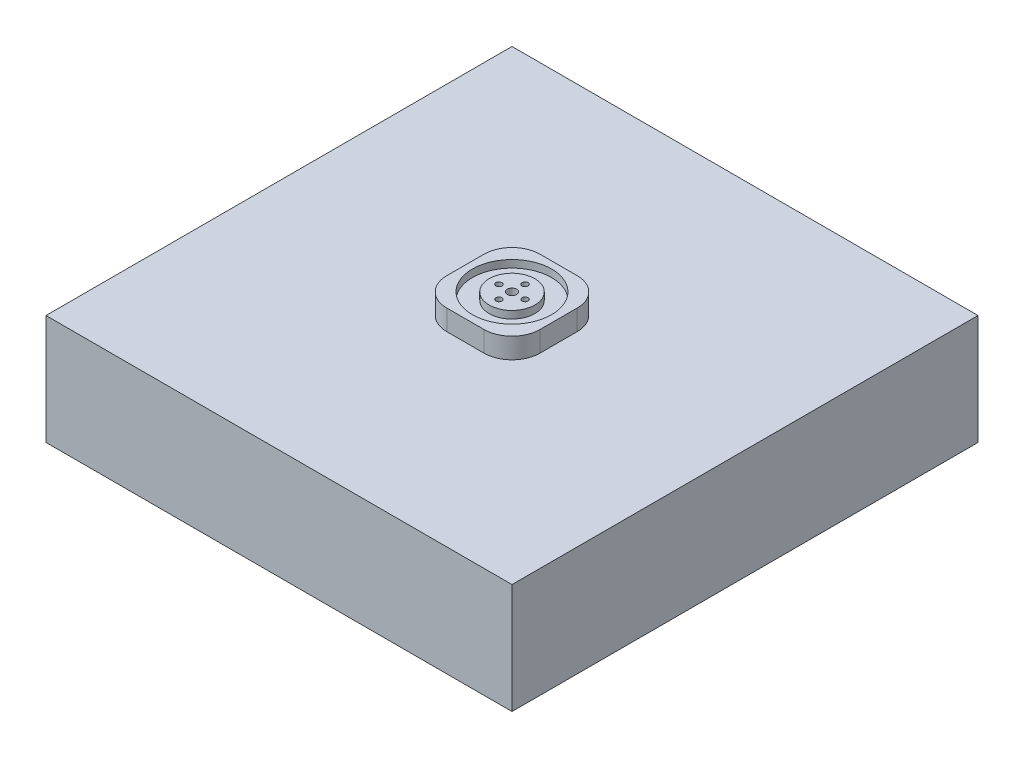
from build123d import *

# Parameters (mm, degrees)
BOSS_EXTRUDE1_DEPTH          = 44
SKETCH3_W                    = 50
SKETCH3_H                    = 50
BOSS_EXTRUDE2_DEPTH          = 11
SKETCH4_R                    = 21.25
SKETCH4_R_2                  = 12.25
CUT_EXTRUDE1_DEPTH           = 4
SKETCH5_3_R                  = 1.6
CUT_EXTRUDE3_DEPTH           = 20
SKETCH5_R                    = 2.5
CUT_EXTRUDE4_DEPTH           = 5
FILLET2_R                    = 15
SKETCH8_R                    = 3
CUT_EXTRUDE5_DEPTH           = 15
SCHIZZO2_W                   = 250
SCHIZZO2_H                   = 250
SCHIZZO2_W_2                 = 25.273765435
SCHIZZO2_H_2                 = 26.723899517
ESTRUSIONE_ESTRUSIONE1_DEPTH = 9
SCHIZZO5_W                   = 250
SCHIZZO5_H                   = 250
SCHIZZO5_W_2                 = 121.71
SCHIZZO5_H_2                 = 121.711825152
ESTRUSIONE_ESTRUSIONE2_DEPTH = 50


with BuildPart() as part:
    # Sketch1 → Boss-Extrude1 (new body)
    with BuildSketch(Plane.XY):
        Polygon((-22.5, 0), (22.5, 0), (18, 9), (-18, 9), align=None)
    extrude(amount=BOSS_EXTRUDE1_DEPTH)

    # Sketch3 → Boss-Extrude2 (add)
    with BuildSketch(Plane(origin=(0, 9, 0), x_dir=(1, 0, 0), z_dir=(0, 1, 0))):
        with Locations((0, -22)):
            Rectangle(SKETCH3_W, SKETCH3_H)
    extrude(amount=BOSS_EXTRUDE2_DEPTH)

    # Sketch4 → Cut-Extrude1 (cut)
    with BuildSketch(Plane(origin=(0, 20, 0), x_dir=(1, 0, 0), z_dir=(0, 1, 0))):
        with Locations((0, -22)):
            Circle(SKETCH4_R)
        with Locations((0, -22)):
            Circle(SKETCH4_R_2, mode=Mode.SUBTRACT)
    extrude(amount=-CUT_EXTRUDE1_DEPTH, mode=Mode.SUBTRACT)

    # Sketch5_3 → Cut-Extrude3 (cut)
    with BuildSketch(Plane(origin=(0, 20, 0), x_dir=(1, 0, 0), z_dir=(0, 1, 0))):
        with Locations((0, -15)):
            Circle(SKETCH5_3_R)
        with Locations((-7, -22)):
            Circle(SKETCH5_3_R)
        with Locations((7, -22)):
            Circle(SKETCH5_3_R)
        with Locations((0, -29)):
            Circle(SKETCH5_3_R)
    extrude(amount=-CUT_EXTRUDE3_DEPTH, mode=Mode.SUBTRACT)

    # Sketch5 → Cut-Extrude4 (cut)
    with BuildSketch(Plane(origin=(0, 20, 0), x_dir=(1, 0, 0), z_dir=(0, 1, 0))):
        with Locations((0, -22)):
            Circle(SKETCH5_R)
    extrude(amount=-CUT_EXTRUDE4_DEPTH, mode=Mode.SUBTRACT)

    # Fillet2
    fillet2_edges = [part.edges().sort_by_distance(p)[0] for p in [
        (25, 14.5, 47),
        (25, 14.5, -3),
        (-25, 14.5, -3),
        (-25, 14.5, 47),
    ]]
    fillet(fillet2_edges, radius=FILLET2_R)

    # Sketch8 → Cut-Extrude5 (cut)
    with BuildSketch(Plane(origin=(0, 0, 0), x_dir=(-1, 0, 0), z_dir=(0, -1, 0))):
        with Locations((0, -29)):
            Circle(SKETCH8_R)
        with Locations((-7, -22)):
            Circle(SKETCH8_R)
        with Locations((0, -15)):
            Circle(SKETCH8_R)
        with Locations((7, -22)):
            Circle(SKETCH8_R)
    extrude(amount=-CUT_EXTRUDE5_DEPTH, mode=Mode.SUBTRACT)

    # Schizzo2 → Estrusione-Estrusione1 (add)
    with BuildSketch(Plane.XZ):
        with Locations((0, 22)):
            Rectangle(SCHIZZO2_W, SCHIZZO2_H)
        with Locations((-0.310743018, 21.585675977)):
            Rectangle(SCHIZZO2_W_2, SCHIZZO2_H_2, mode=Mode.SUBTRACT)
    extrude(amount=-ESTRUSIONE_ESTRUSIONE1_DEPTH)

    # Schizzo5 → Estrusione-Estrusione2 (add)
    with BuildSketch(Plane.XZ):
        with Locations((0, 22)):
            Rectangle(SCHIZZO5_W, SCHIZZO5_H)
        with Locations((0, 22)):
            Rectangle(SCHIZZO5_W_2, SCHIZZO5_H_2, mode=Mode.SUBTRACT)
    extrude(amount=ESTRUSIONE_ESTRUSIONE2_DEPTH)


solid = part.part
